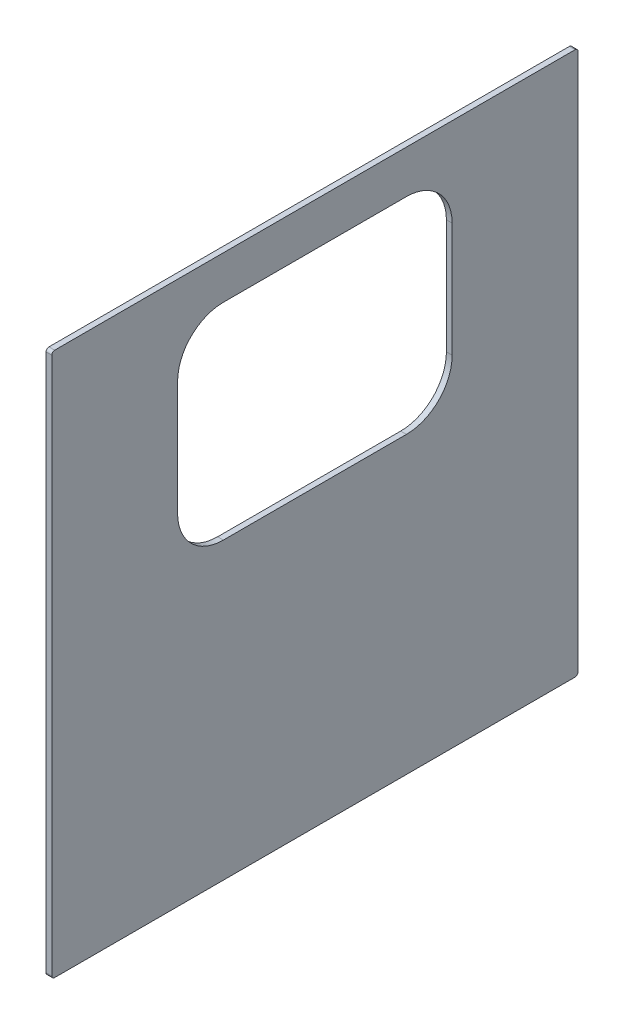
from build123d import *

# Parameters (mm, degrees)
BOSS_EXTRUDE1_DEPTH = 12.7


with BuildPart() as part:
    # Sketch1 → Boss-Extrude1 (new body)
    with BuildSketch(Plane(origin=(0, 0, 0), x_dir=(0, 0, -1), z_dir=(1, 0, 0))):
        with BuildLine():
            Line((6.35, 0), (1162.05, 0))
            ThreePointArc((1162.05, 0), (1166.540128061, 1.859871939), (1168.4, 6.35))
            Line((1168.4, 6.35), (1168.4, 1200.15))
            ThreePointArc((1168.4, 1200.15), (1166.540128061, 1204.640128061), (1162.05, 1206.5))
            Line((1162.05, 1206.5), (6.35, 1206.5))
            ThreePointArc((6.35, 1206.5), (1.859871939, 1204.640128061), (0, 1200.15))
            Line((0, 1200.15), (0, 6.35))
            ThreePointArc((0, 6.35), (1.859871939, 1.859871939), (6.35, 0))
        make_face()
        with BuildLine():
            Line((381, 1111.25), (787.4, 1111.25))
            ThreePointArc((787.4, 1111.25), (859.242048969, 1081.492048969), (889, 1009.65))
            Line((889, 1009.65), (889, 755.65))
            ThreePointArc((889, 755.65), (859.242048969, 683.807951031), (787.4, 654.05))
            Line((787.4, 654.05), (381, 654.05))
            ThreePointArc((381, 654.05), (309.157951031, 683.807951031), (279.4, 755.65))
            Line((279.4, 755.65), (279.4, 1009.65))
            ThreePointArc((279.4, 1009.65), (309.157951031, 1081.492048969), (381, 1111.25))
        make_face(mode=Mode.SUBTRACT)
    extrude(amount=BOSS_EXTRUDE1_DEPTH)


solid = part.part
